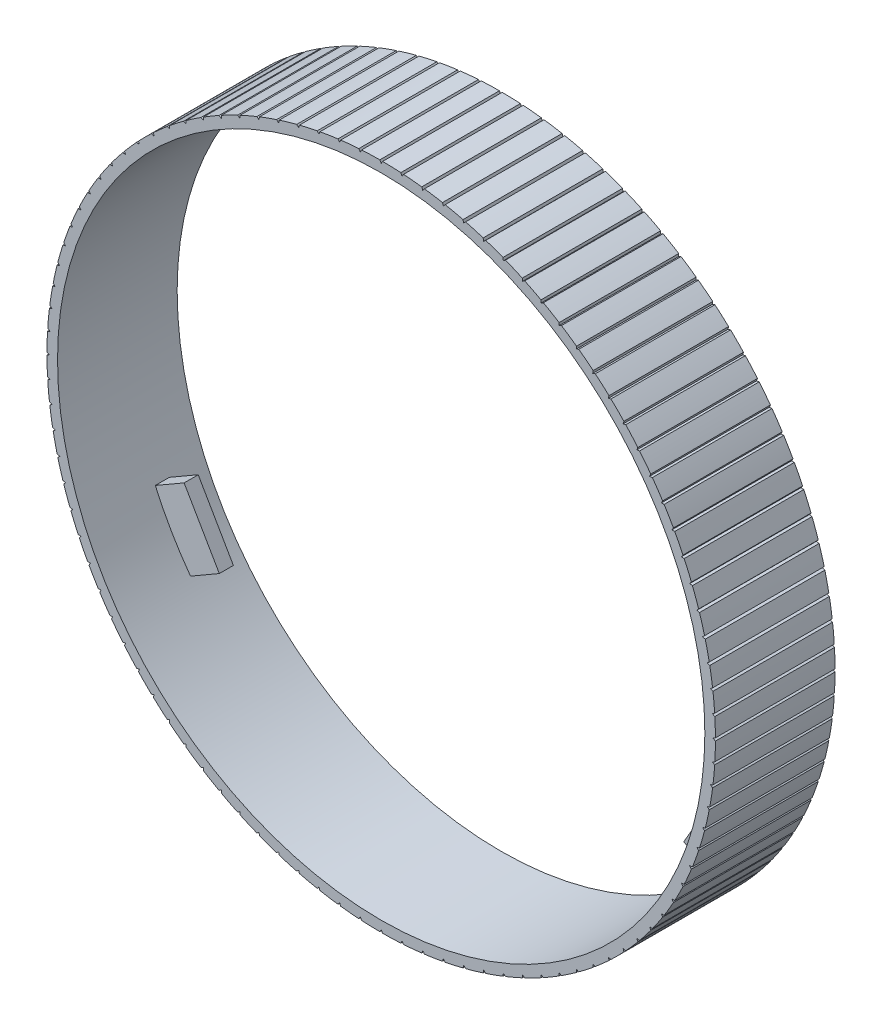
from build123d import *

# Parameters (mm, degrees)
BOSS_EXTRUDE1_DEPTH      = 11
BOSS_EXTRUDE1_DEPTH_BACK = 6
SKETCH2_R                = 47.5
SKETCH2_R_2              = 46
SKETCH2_4_W              = 10
SKETCH2_4_H              = 5
BOSS_EXTRUDE2_DEPTH      = 1
CIRPATTERN1_COUNT        = 3
CUT_EXTRUDE1_DEPTH       = 70.292856775
CIRPATTERN2_COUNT        = 100


with BuildPart() as part:
    # Sketch2 → Boss-Extrude1 (new, two sides: drawn at the far end of the back side and taken through both)
    with BuildSketch(Plane.XY.offset(-BOSS_EXTRUDE1_DEPTH_BACK)):
        Circle(SKETCH2_R)
        Circle(SKETCH2_R_2, mode=Mode.SUBTRACT)
    extrude(amount=BOSS_EXTRUDE1_DEPTH + BOSS_EXTRUDE1_DEPTH_BACK)

    # Sketch2_4 → Boss-Extrude2 (add, symmetric)
    with BuildSketch(Plane.XY):
        with Locations((0, 43.5)):
            Rectangle(SKETCH2_4_W, SKETCH2_4_H)
    boss_extrude2 = extrude(amount=BOSS_EXTRUDE2_DEPTH, both=True)

    # CirPattern1: Boss-Extrude2 ×3 about axis
    cirpattern1_axis = Axis((0, 0, -6), (0, 0, 1))
    for i in range(1, CIRPATTERN1_COUNT):
        add(boss_extrude2.rotate(cirpattern1_axis, i * 360 / CIRPATTERN1_COUNT))

    # Sketch3 → Cut-Extrude1 (cut, through all)
    with BuildSketch(Plane(origin=(0, 0, -6), x_dir=(-1, 0, 0), z_dir=(0, 0, -1))):
        Polygon((47.668608992, -0.292039342), (47.668608992, 0.292039342), (47.162782015, 0), align=None)
    cut_extrude1 = extrude(amount=-CUT_EXTRUDE1_DEPTH, mode=Mode.SUBTRACT)

    # CirPattern2: Cut-Extrude1 ×100 about axis
    cirpattern2_axis = Axis((0, 0, -6), (0, 0, 1))
    for i in range(1, CIRPATTERN2_COUNT):
        add(cut_extrude1.rotate(cirpattern2_axis, i * 360 / CIRPATTERN2_COUNT), mode=Mode.SUBTRACT)


solid = part.part
